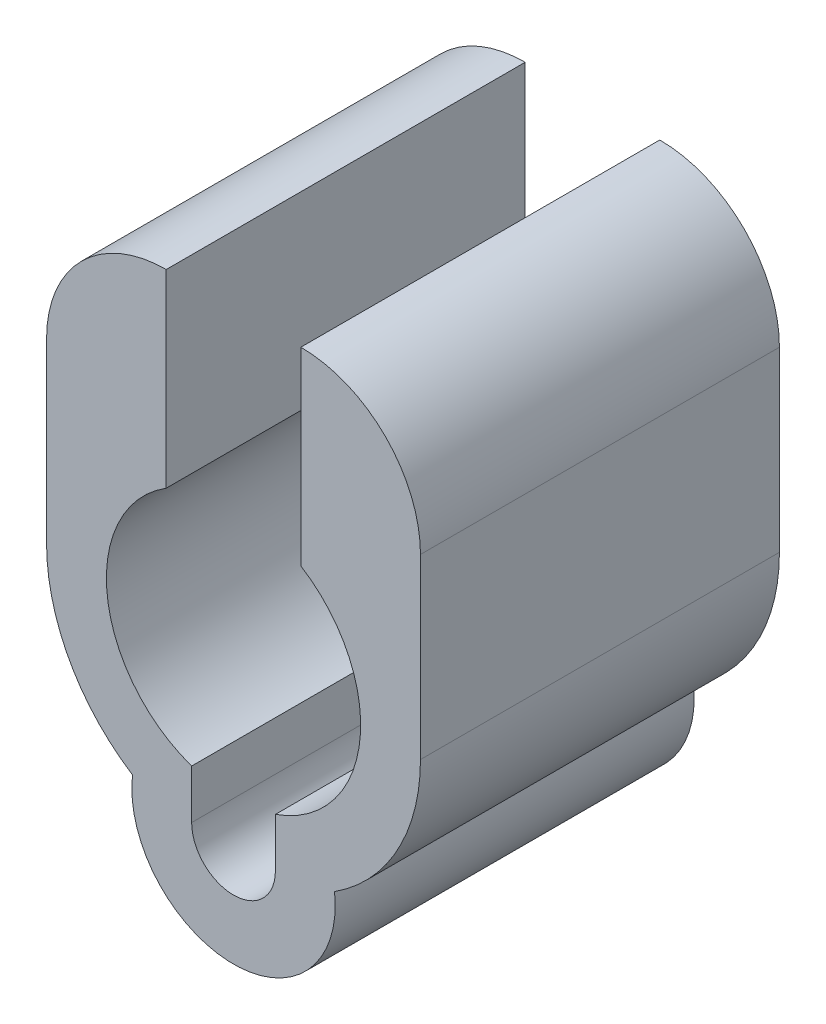
from build123d import *

# Parameters (mm, degrees)
BOSS_EXTRUDE1_DEPTH = 10
BOSS_EXTRUDE2_START = -2
BOSS_EXTRUDE2_DEPTH = 2


with BuildPart() as part:
    # Sketch1 → Boss-Extrude1 (new body)
    with BuildSketch(Plane.XY):
        with BuildLine():
            Line((2.25, 5.018714975), (2.25, 3.605551275))
            ThreePointArc((2.25, 3.605551275), (4.223791394, -0.47126029), (1.4, -4.012792045))
            Line((1.4, -4.012792045), (1.4, -5.65))
            ThreePointArc((1.4, -5.65), (0, -7.05), (-1.4, -5.65))
            Line((-1.4, -5.65), (-1.4, -4.012792045))
            ThreePointArc((-1.4, -4.012792045), (-4.223791394, -0.47126029), (-2.25, 3.605551275))
            Line((-2.25, 3.605551275), (-2.25, 5.018714975))
            Line((-2.25, 5.018714975), (-2.25, 9.937240371))
            ThreePointArc((-2.25, 9.937240371), (-5.078427125, 8.765667496), (-6.25, 5.937240371))
            Line((-6.25, 5.937240371), (-6.25, 0))
            ThreePointArc((-6.25, 0), (-5.485043656, -2.996130185), (-3.377425252, -5.258849558))
            ThreePointArc((-3.377425252, -5.258849558), (0, -9.05), (3.377425252, -5.258849558))
            ThreePointArc((3.377425252, -5.258849558), (5.485043656, -2.996130185), (6.25, 0))
            Line((6.25, 0), (6.25, 5.937240371))
            ThreePointArc((6.25, 5.937240371), (5.078427125, 8.765667496), (2.25, 9.937240371))
            Line((2.25, 9.937240371), (2.25, 5.018714975))
        make_face()
    extrude(amount=BOSS_EXTRUDE1_DEPTH)

    # Sketch1_5 → Boss-Extrude2 (add)
    with BuildSketch(Plane.XY.offset(BOSS_EXTRUDE2_START)):
        with BuildLine():
            Line((2.25, 5.018714975), (2.25, 3.605551275))
            ThreePointArc((2.25, 3.605551275), (4.223791394, -0.47126029), (1.4, -4.012792045))
            Line((1.4, -4.012792045), (1.4, -5.65))
            ThreePointArc((1.4, -5.65), (0, -7.05), (-1.4, -5.65))
            Line((-1.4, -5.65), (-1.4, -4.012792045))
            ThreePointArc((-1.4, -4.012792045), (-4.223791394, -0.47126029), (-2.25, 3.605551275))
            Line((-2.25, 3.605551275), (-2.25, 5.018714975))
            Line((-2.25, 5.018714975), (-2.25, 9.937240371))
            ThreePointArc((-2.25, 9.937240371), (-5.078427125, 8.765667496), (-6.25, 5.937240371))
            Line((-6.25, 5.937240371), (-6.25, 0))
            ThreePointArc((-6.25, 0), (-5.485043656, -2.996130185), (-3.377425252, -5.258849558))
            ThreePointArc((-3.377425252, -5.258849558), (0, -9.05), (3.377425252, -5.258849558))
            ThreePointArc((3.377425252, -5.258849558), (5.485043656, -2.996130185), (6.25, 0))
            Line((6.25, 0), (6.25, 5.937240371))
            ThreePointArc((6.25, 5.937240371), (5.078427125, 8.765667496), (2.25, 9.937240371))
            Line((2.25, 9.937240371), (2.25, 5.018714975))
        make_face()
    extrude(amount=BOSS_EXTRUDE2_DEPTH)


solid = part.part
